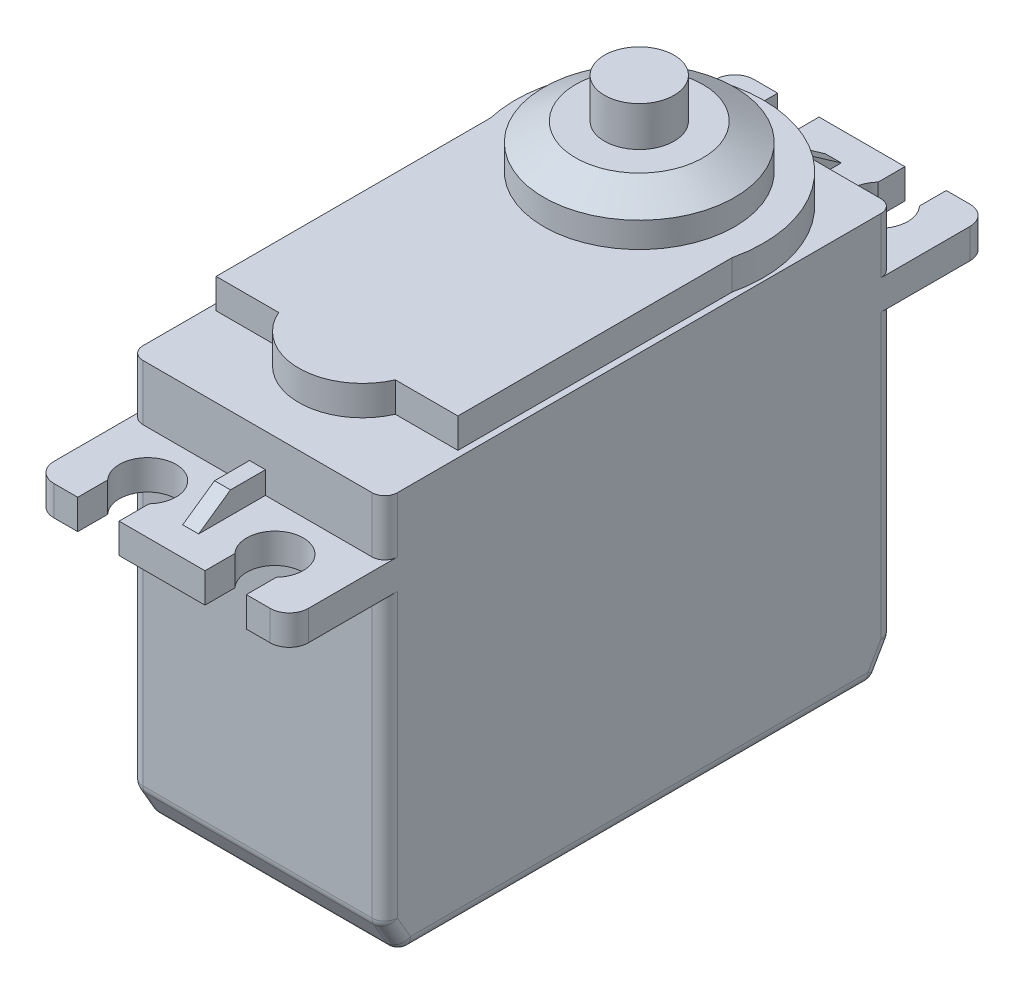
from build123d import *

# Parameters (mm, degrees)
SKETCH1_W             = 20.32
SKETCH1_H             = 40.64
EXTRUDE1_DEPTH        = 25.4
SKETCH2_W             = 20.32
SKETCH2_H             = 40.64
EXTRUDE2_DEPTH        = 2.38125
SKETCH3_W             = 20.32
SKETCH3_H             = 40.64
EXTRUDE3_DEPTH        = 4.445
EXTRUDE4_DEPTH        = 2.38125
SKETCH5_R             = 7.62
EXTRUDE5_DEPTH        = 3.4925
CHAMFER1_SIZE         = 2.54
CHAMFER1_SIZE2        = 1.466469684
EXTRUDE6_DEPTH        = 0.635
SKETCH8_R             = 2.778125
EXTRUDE7_DEPTH        = 3.175
CHAMFER2_SIZE         = 2.54
CHAMFER2_SIZE2        = 1.466469684
CHAMFER2_PART_2_SIZE  = 2.54
CHAMFER2_PART_2_SIZE2 = 1.466469684
FILLET1_R             = 1.016
FILLET2_R             = 1.524
SKETCH9_W             = 6.35
SKETCH9_H             = 2.54
EXTRUDE8_DEPTH        = 2.38125
SKETCH10_W            = 5.08
SKETCH10_H            = 1.27
CUT_EXTRUDE1_DEPTH    = 2.38125


with BuildPart() as part:
    # Sketch1 → Extrude1 (new body)
    with BuildSketch(Plane(origin=(0, 0, 0), x_dir=(1, 0, 0), z_dir=(0, 1, 0))):
        with Locations((0, -10.16)):
            Rectangle(SKETCH1_W, SKETCH1_H)
    extrude(amount=EXTRUDE1_DEPTH)

    # Sketch2 → Extrude2 (add)
    with BuildSketch(Plane(origin=(0, 25.4, 0), x_dir=(-1, 0, 0), z_dir=(0, 1, 0))):
        with Locations((0, 10.16)):
            Rectangle(SKETCH2_W, SKETCH2_H)
        with BuildLine():
            ThreePointArc((6.731, -15.64118631), (5.08, -11.8364), (3.429, -15.64118631))
            Line((3.429, -15.64118631), (3.429, -17.78))
            Line((3.429, -17.78), (-3.429, -17.78))
            Line((-3.429, -17.78), (-3.429, -15.64118631))
            ThreePointArc((-3.429, -15.64118631), (-5.08, -11.8364), (-6.731, -15.64118631))
            Line((-6.731, -15.64118631), (-6.731, -17.78))
            Line((-6.731, -17.78), (-10.16, -17.78))
            Line((-10.16, -17.78), (-10.16, -10.16))
            Line((-10.16, -10.16), (10.16, -10.16))
            Line((10.16, -10.16), (10.16, -17.78))
            Line((10.16, -17.78), (6.731, -17.78))
            Line((6.731, -17.78), (6.731, -15.64118631))
        make_face()
        with BuildLine():
            ThreePointArc((-6.731, 35.70718631), (-5.08, 31.9024), (-3.429, 35.70718631))
            Line((-3.429, 35.70718631), (-3.429, 38.1))
            Line((-3.429, 38.1), (3.429, 38.1))
            Line((3.429, 38.1), (3.429, 35.70718631))
            ThreePointArc((3.429, 35.70718631), (5.08, 31.9024), (6.731, 35.70718631))
            Line((6.731, 35.70718631), (6.731, 38.1))
            Line((6.731, 38.1), (10.16, 38.1))
            Line((10.16, 38.1), (10.16, 30.48))
            Line((10.16, 30.48), (-10.16, 30.48))
            Line((-10.16, 30.48), (-10.16, 38.1))
            Line((-10.16, 38.1), (-6.731, 38.1))
            Line((-6.731, 38.1), (-6.731, 35.70718631))
        make_face()
    extrude(amount=EXTRUDE2_DEPTH)

    # Sketch3 → Extrude3 (add)
    with BuildSketch(Plane(origin=(0, 27.78125, 0), x_dir=(-1, 0, 0), z_dir=(0, 1, 0))):
        with Locations((0, 10.16)):
            Rectangle(SKETCH3_W, SKETCH3_H)
    extrude(amount=EXTRUDE3_DEPTH)

    # Sketch4 → Extrude4 (add)
    with BuildSketch(Plane(origin=(0, 32.22625, 0), x_dir=(-1, 0, 0), z_dir=(0, 1, 0))):
        with BuildLine():
            Line((9.652, 2.228840954), (9.652, 24.13))
            Line((9.652, 24.13), (4.655896906, 24.13))
            ThreePointArc((4.655896906, 24.13), (0, 27.178), (-4.655896906, 24.13))
            Line((-4.655896906, 24.13), (-9.652, 24.13))
            Line((-9.652, 24.13), (-9.652, 2.228840954))
            ThreePointArc((-9.652, 2.228840954), (0, -9.906), (9.652, 2.228840954))
        make_face()
    extrude(amount=EXTRUDE4_DEPTH)

    # Sketch5 → Extrude5 (add)
    with BuildSketch(Plane(origin=(0, 34.6075, 0), x_dir=(-1, 0, 0), z_dir=(0, 1, 0))):
        Circle(SKETCH5_R)
    extrude(amount=EXTRUDE5_DEPTH)

    # Chamfer1
    chamfer1_edges = [part.edges().sort_by_distance(p)[0] for p in [
        (7.62, 38.1, 0),
    ]]
    chamfer1_side = [part.faces().sort_by_distance(p)[0] for p in [
        (0, 38.1, 0),
    ]]
    chamfer(chamfer1_edges, length=CHAMFER1_SIZE, length2=CHAMFER1_SIZE2, reference=chamfer1_side[0])

    # Sketch7 → Extrude6 (add, symmetric)
    with BuildSketch(Plane(origin=(0, 0, 0), x_dir=(0, 0, -1), z_dir=(1, 0, 0))):
        Polygon((15.494, 27.78125), (12.954, 29.55925), (10.16, 29.55925), (10.16, 27.78125), align=None)
    extrude6 = extrude(amount=EXTRUDE6_DEPTH, both=True)

    # Mirror1: Extrude6 across plane
    add(extrude6.mirror(Plane(origin=(0, 0, 10.16), x_dir=(1, 0, 0), z_dir=(0, 0, -1))))

    # Sketch8 → Extrude7 (add)
    with BuildSketch(Plane(origin=(0, 38.1, 0), x_dir=(-1, 0, 0), z_dir=(0, 1, 0))):
        Circle(SKETCH8_R)
    extrude(amount=EXTRUDE7_DEPTH)

    # Chamfer2
    chamfer2_edges = [part.edges().sort_by_distance(p)[0] for p in [
        (0, 0, -10.16),
    ]]
    chamfer2_side = [part.faces().sort_by_distance(p)[0] for p in [
        (0, 12.7, -10.16),
    ]]
    chamfer(chamfer2_edges, length=CHAMFER2_SIZE, length2=CHAMFER2_SIZE2, reference=chamfer2_side[0])

    # Chamfer2 part 2
    chamfer2_part_2_edges = [part.edges().sort_by_distance(p)[0] for p in [
        (0, 0, 30.48),
    ]]
    chamfer2_part_2_side = [part.faces().sort_by_distance(p)[0] for p in [
        (0, 12.7, 30.48),
    ]]
    chamfer(chamfer2_part_2_edges, length=CHAMFER2_PART_2_SIZE, length2=CHAMFER2_PART_2_SIZE2, reference=chamfer2_part_2_side[0])

    # Fillet1
    fillet1_edges = [part.edges().sort_by_distance(p)[0] for p in [
        (-10.16, 30.00375, -10.16),
        (10.16, 30.00375, -10.16),
        (10.16, 30.00375, 30.48),
        (10.16, 0, 10.16),
        (10.16, 1.27, -9.426765158),
        (10.16, 13.97, -10.16),
        (0, 0, -8.693530316),
        (0, 2.54, -10.16),
        (-10.16, 13.97, -10.16),
        (-10.16, 1.27, -9.426765158),
        (10.16, 13.97, 30.48),
        (10.16, 1.27, 29.746765158),
        (0, 2.54, 30.48),
        (-10.16, 0, 10.16),
        (0, 0, 29.013530316),
        (-10.16, 1.27, 29.746765158),
        (-10.16, 13.97, 30.48),
        (-10.16, 30.00375, 30.48),
    ]]
    fillet(fillet1_edges, radius=FILLET1_R)

    # Fillet2
    fillet2_edges = [part.edges().sort_by_distance(p)[0] for p in [
        (-10.16, 26.590625, 38.1),
        (10.16, 26.590625, 38.1),
        (-10.16, 26.590625, -17.78),
        (10.16, 26.590625, -17.78),
    ]]
    fillet(fillet2_edges, radius=FILLET2_R)

    # Sketch9 → Extrude8 (add)
    with BuildSketch(Plane(origin=(0, 0, -10.16), x_dir=(-1, 0, 0), z_dir=(0, 0, -1))):
        with Locations((0, 4.318)):
            Rectangle(SKETCH9_W, SKETCH9_H)
    extrude(amount=EXTRUDE8_DEPTH)

    # Sketch10 → Cut-Extrude1 (cut)
    with BuildSketch(Plane(origin=(0, 0, -12.54125), x_dir=(-1, 0, 0), z_dir=(0, 0, -1))):
        with Locations((0, 4.318)):
            Rectangle(SKETCH10_W, SKETCH10_H)
    extrude(amount=-CUT_EXTRUDE1_DEPTH, mode=Mode.SUBTRACT)


solid = part.part
